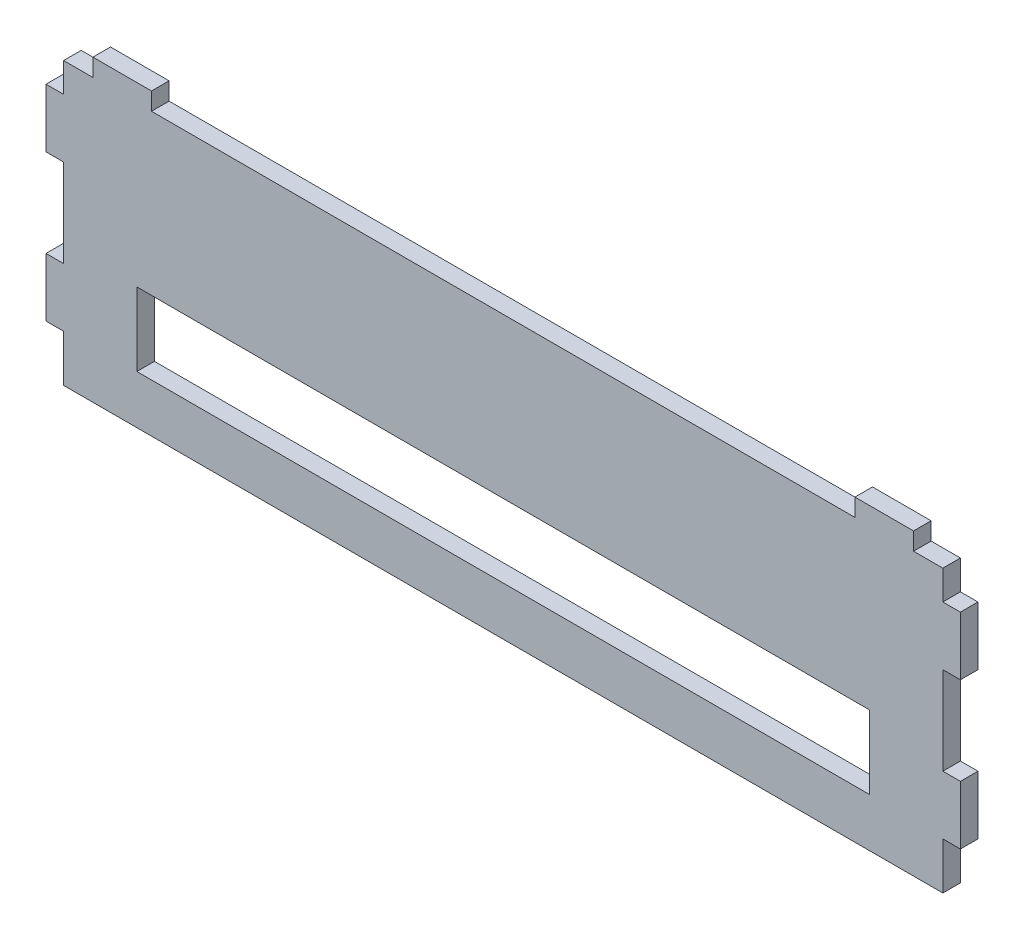
from build123d import *

# Parameters (mm, degrees)
SKETCH1_W           = 250
SKETCH1_H           = 25
BOSS_EXTRUDE1_DEPTH = 6


with BuildPart() as part:
    # Sketch1 → Boss-Extrude1 (new body)
    with BuildSketch(Plane.XY):
        Polygon((495.568859933, -96.000000001), (195.568859933, -96.000000001), (195.568859933, -80.000000001), (189.568859933, -80.000000001), (189.568859933, -60.000000001), (195.568859933, -60.000000001), (195.568859933, -30.000000001), (189.568859933, -30.000000001), (189.568859933, -10.000000001), (195.568859933, -10.000000001), (195.568859933, 0), (205.568859933, 0), (205.568859933, 6), (225.568859933, 6), (225.568859933, 0), (465.568859933, 0), (465.568859933, 6), (485.568859933, 6), (485.568859933, 0), (495.568859933, 0), (495.568859933, -10), (501.568859933, -10), (501.568859933, -30), (495.568859933, -30), (495.568859933, -60), (501.568859933, -60), (501.568859933, -80), (495.568859933, -80), align=None)
        with Locations((345.568859933, -66.9)):
            Rectangle(SKETCH1_W, SKETCH1_H, mode=Mode.SUBTRACT)
    extrude(amount=-BOSS_EXTRUDE1_DEPTH)


solid = part.part
